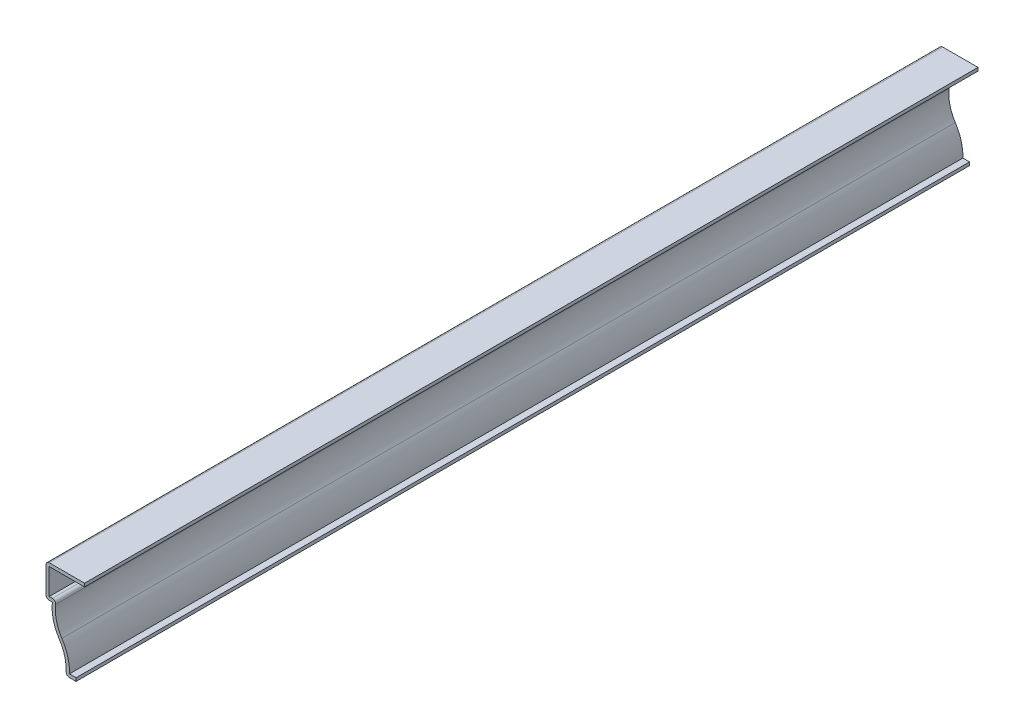
from build123d import *

# Parameters (mm, degrees)
EXTRUDE_THIN1_DEPTH = 349.25
FILLET1_R           = 1.27


with BuildPart() as part:
    # Sketch1 → Extrude-Thin1 (new body)
    with BuildSketch(Plane.XY):
        with BuildLine():
            Line((0, 34.925), (-15.08125, 34.925))
            Line((-15.08125, 34.925), (-15.08125, 22.225))
            Line((-15.08125, 22.225), (-12.589163559, 22.225))
            ThreePointArc((-12.589163559, 22.225), (-12.244128802, 16.434292536), (-9.935478518, 11.1125))
            ThreePointArc((-9.935478518, 11.1125), (-7.626828235, 5.790707464), (-7.281793478, 0))
            Line((-7.281793478, 0), (-3.313043478, 0))
            Line((-3.313043478, 0), (-3.313043478, 1.27))
            Line((-3.313043478, 1.27), (-5.912702406, 1.27))
            ThreePointArc((-5.912702406, 1.27), (-6.570184472, 6.773148448), (-8.876108727, 11.812953884))
            ThreePointArc((-8.876108727, 11.812953884), (-11.159248724, 17.431038769), (-11.096159817, 23.495))
            Line((-11.096159817, 23.495), (-13.81125, 23.495))
            Line((-13.81125, 23.495), (-13.81125, 33.655))
            Line((-13.81125, 33.655), (0, 33.655))
            Line((0, 33.655), (0, 34.925))
        make_face()
    extrude(amount=-EXTRUDE_THIN1_DEPTH)

    # Fillet1
    fillet1_edges = [part.edges().sort_by_distance(p)[0] for p in [
        (-7.281793478, 0, -174.625),
        (-15.08125, 22.225, -174.625),
        (-15.08125, 34.925, -174.625),
        (-11.096159817, 23.495, -174.625),
    ]]
    fillet(fillet1_edges, radius=FILLET1_R)


solid = part.part
